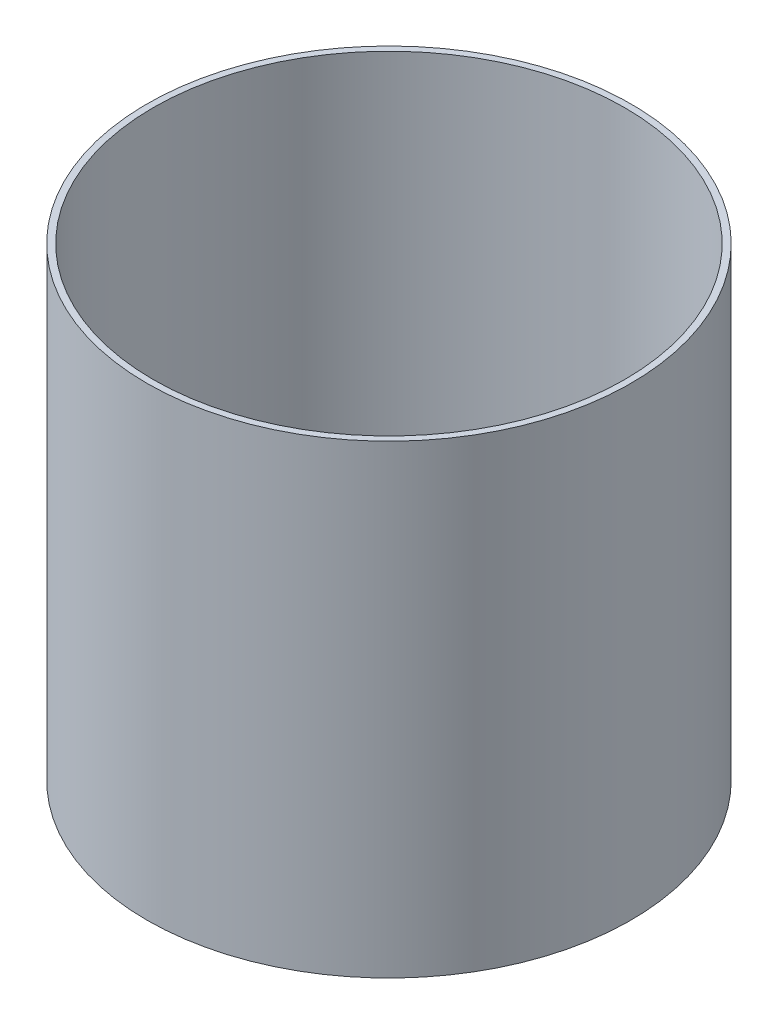
from build123d import *

# Parameters (mm, degrees)
SKETCH_1_R      = 19
SKETCH_1_R_2    = 18.5
EXTRUDE_1_DEPTH = 36.5


with BuildPart() as part:
    # 草图1 → 凸台-拉伸1 (new body)
    with BuildSketch(Plane(origin=(0, 0, 0), x_dir=(1, 0, 0), z_dir=(0, 1, 0))):
        Circle(SKETCH_1_R)
        Circle(SKETCH_1_R_2, mode=Mode.SUBTRACT)
    extrude(amount=EXTRUDE_1_DEPTH)


solid = part.part
